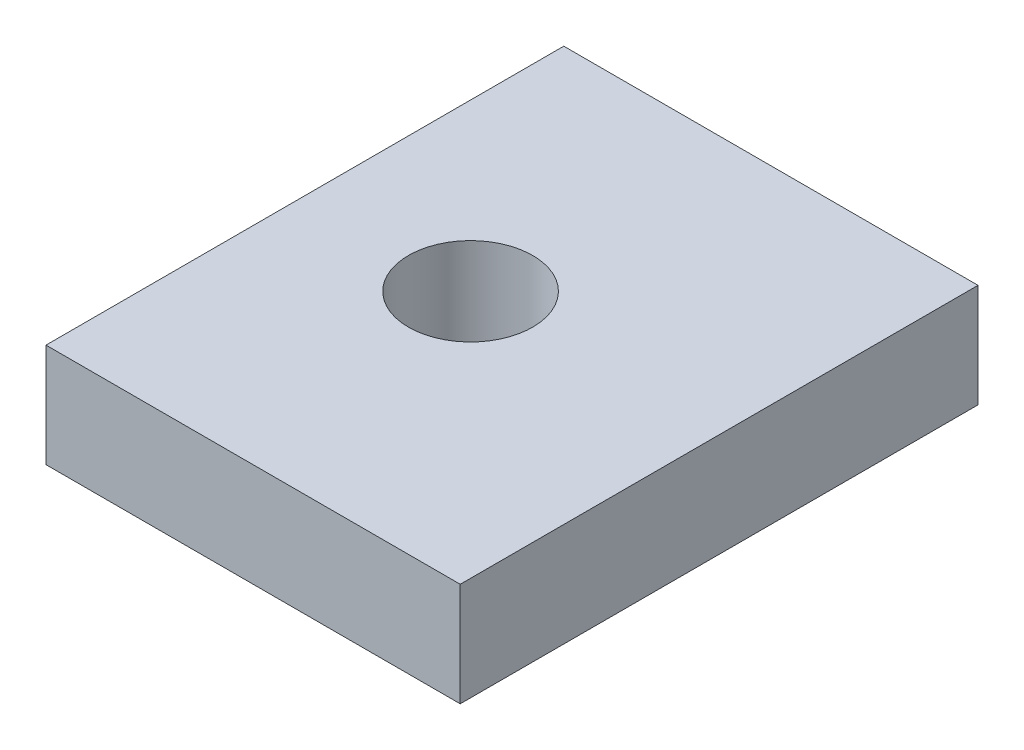
from build123d import *

# Parameters (mm, degrees)
ESQUISSE1_W             = 20
ESQUISSE1_H             = 5
BOSS_EXTRU_1_DEPTH      = 25
ESQUISSE2_R             = 3
ENL_V_MAT_EXTRU_1_DEPTH = 6


with BuildPart() as part:
    # Esquisse1 → Boss.-Extru.1 (new body)
    with BuildSketch(Plane.XY):
        with Locations((10, -2.5)):
            Rectangle(ESQUISSE1_W, ESQUISSE1_H)
    extrude(amount=BOSS_EXTRU_1_DEPTH)

    # Esquisse2 → Enlèv. mat.-Extru.1 (cut, through all)
    with BuildSketch(Plane(origin=(0, 0, 0), x_dir=(1, 0, 0), z_dir=(0, 1, 0))):
        with Locations((8, -12.5)):
            Circle(ESQUISSE2_R)
    extrude(amount=-ENL_V_MAT_EXTRU_1_DEPTH, mode=Mode.SUBTRACT)


solid = part.part
